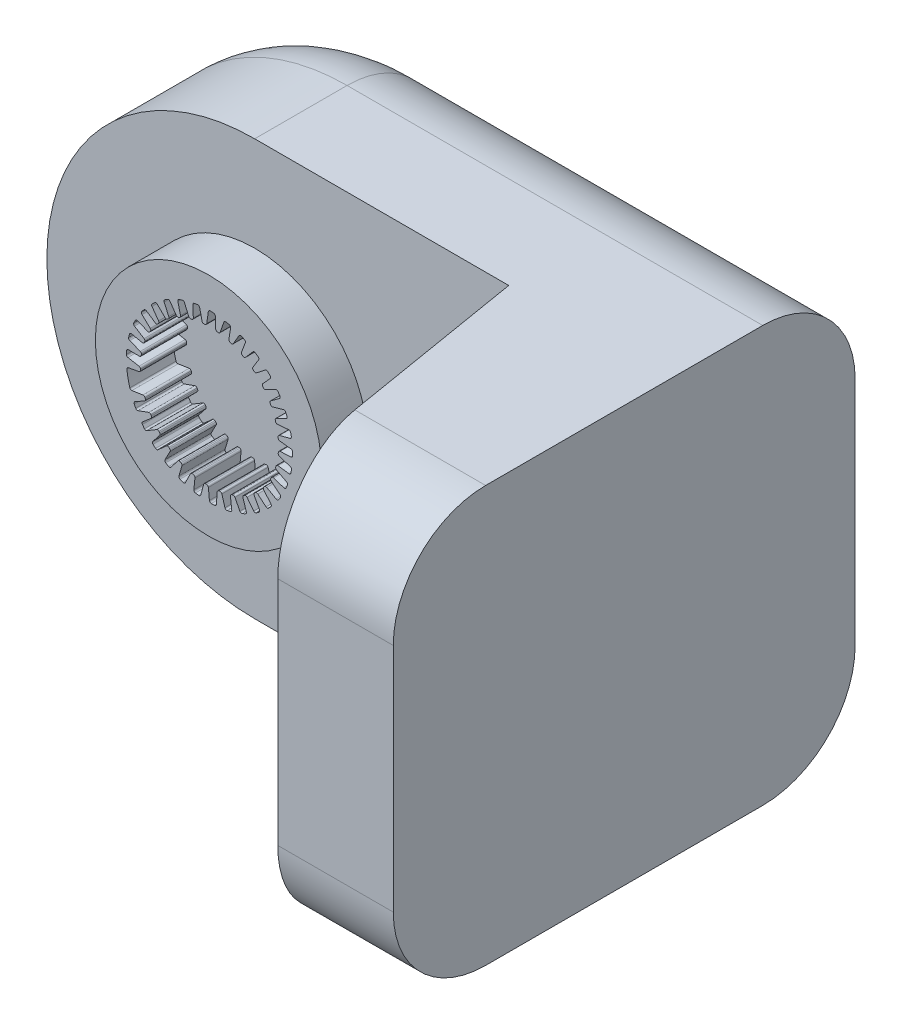
from build123d import *

# Parameters (mm, degrees)
SKETCH1_R           = 24.5
BOSS_EXTRUDE1_DEPTH = 10
BOSS_EXTRUDE3_DEPTH = 40
SKETCH7_W           = 35
SKETCH7_H           = 90
BOSS_EXTRUDE4_DEPTH = 60
CUT_EXTRUDE1_DEPTH  = 91
FILLET1_R           = 20
FILLET2_R           = 20


with BuildPart() as part:
    # Sketch1 → Boss-Extrude1 (new body)
    with BuildSketch(Plane.XY):
        with Locations((-0.371975008, 0)):
            Circle(SKETCH1_R)
        with BuildLine():
            Line((-16.969142825, -5.497864624), (-14.564977721, -5.124585631))
            ThreePointArc((-14.564977721, -5.124585631), (-14.29707046, -5.177296982), (-14.125400218, -5.389622476))
            Line((-14.125400218, -5.389622476), (-14.049847687, -5.60904296))
            ThreePointArc((-14.049847687, -5.60904296), (-14.054138659, -5.881349365), (-14.231761388, -6.087793926))
            Line((-14.231761388, -6.087793926), (-16.278130424, -7.240339372))
            ThreePointArc((-16.278130424, -7.240339372), (-16.462911631, -7.467282264), (-16.443705401, -7.759306734))
            ThreePointArc((-16.443705401, -7.759306734), (-16.284490349, -8.088614134), (-16.11861668, -8.414618309))
            ThreePointArc((-16.11861668, -8.414618309), (-15.909353928, -8.602256969), (-15.62830969, -8.605904202))
            Line((-15.62830969, -8.605904202), (-13.33954086, -7.780747067))
            ThreePointArc((-13.33954086, -7.780747067), (-13.06649801, -7.781370848), (-12.857468219, -7.957039097))
            Line((-12.857468219, -7.957039097), (-12.741436398, -8.158012106))
            ThreePointArc((-12.741436398, -8.158012106), (-12.693690022, -8.426134232), (-12.828657842, -8.662677839))
            Line((-12.828657842, -8.662677839), (-14.617513276, -10.1845134))
            ThreePointArc((-14.617513276, -10.1845134), (-14.755596786, -10.442544627), (-14.681022533, -10.725539064))
            ThreePointArc((-14.681022533, -10.725539064), (-14.461897897, -11.018416496), (-14.236867265, -11.306780868))
            ThreePointArc((-14.236867265, -11.306780868), (-13.995646114, -11.451042861), (-13.719069526, -11.400997316))
            Line((-13.719069526, -11.400997316), (-11.62979923, -10.15428296))
            ThreePointArc((-11.62979923, -10.15428296), (-11.361653923, -10.102796248), (-11.122945516, -10.235352213))
            Line((-11.122945516, -10.235352213), (-10.970698069, -10.410492867))
            ThreePointArc((-10.970698069, -10.410492867), (-10.872668815, -10.664578395), (-10.960022248, -10.922529105))
            Line((-10.960022248, -10.922529105), (-12.425631454, -12.757733968))
            ThreePointArc((-12.425631454, -12.757733968), (-12.511943302, -13.037372011), (-12.384741304, -13.300937604))
            ThreePointArc((-12.384741304, -13.300937604), (-12.113758956, -13.546623101), (-11.837840254, -13.786751538))
            ThreePointArc((-11.837840254, -13.786751538), (-11.57352453, -13.882335867), (-11.311578572, -13.780436499))
            Line((-11.311578572, -13.780436499), (-9.49857837, -12.157976231))
            ThreePointArc((-9.49857837, -12.157976231), (-9.245183775, -12.056270938), (-8.985568244, -12.140843765))
            Line((-8.985568244, -12.140843765), (-8.802699599, -12.28371641))
            ThreePointArc((-8.802699599, -12.28371641), (-8.657989614, -12.514428808), (-8.694518802, -12.784308057))
            Line((-8.694518802, -12.784308057), (-9.783027044, -14.865446458))
            ThreePointArc((-9.783027044, -14.865446458), (-9.814395646, -15.15641584), (-9.63924002, -15.390867705))
            ThreePointArc((-9.63924002, -15.390867705), (-9.326357378, -15.580333398), (-9.009689414, -15.763402229))
            ThreePointArc((-9.009689414, -15.763402229), (-8.731991565, -15.806796587), (-8.494301608, -15.656787752))
            Line((-8.494301608, -15.656787752), (-7.02419134, -13.718199902))
            ThreePointArc((-7.02419134, -13.718199902), (-6.794858602, -13.570013254), (-6.523875683, -13.603495261))
            Line((-6.523875683, -13.603495261), (-6.317105464, -13.70884995))
            ThreePointArc((-6.317105464, -13.70884995), (-6.131032208, -13.907711545), (-6.115394864, -14.179602449))
            Line((-6.115394864, -14.179602449), (-6.786804216, -16.430201641))
            ThreePointArc((-6.786804216, -16.430201641), (-6.762076913, -16.721810507), (-6.545403865, -16.918533562))
            ThreePointArc((-6.545403865, -16.918533562), (-6.202118, -17.044817414), (-5.856336939, -17.164099659))
            ThreePointArc((-5.856336939, -17.164099659), (-5.575461147, -17.153709492), (-5.370761259, -16.96110336))
            Line((-5.370761259, -16.96110336), (-4.297561057, -14.777622566))
            ThreePointArc((-4.297561057, -14.777622566), (-4.100717154, -14.588399775), (-3.828324286, -14.569560645))
            Line((-3.828324286, -14.569560645), (-3.605250396, -14.633526053))
            ThreePointArc((-3.605250396, -14.633526053), (-3.384651249, -14.79322955), (-3.317421976, -15.057141307))
            Line((-3.317421976, -15.057141307), (-3.547061077, -17.394501596))
            ThreePointArc((-3.547061077, -17.394501596), (-3.467146489, -17.676034594), (-3.216917807, -17.827800126))
            ThreePointArc((-3.216917807, -17.827800126), (-2.855842975, -17.886261756), (-2.49365476, -17.937374314))
            ThreePointArc((-2.49365476, -17.937374314), (-2.219921985, -17.873581416), (-2.055733994, -17.645455421))
            Line((-2.055733994, -17.645455421), (-1.418879279, -15.297315067))
            ThreePointArc((-1.418879279, -15.297315067), (-1.261757363, -15.074009244), (-0.997963795, -15.003541232))
            Line((-0.997963795, -15.003541232), (-0.766783225, -15.023766911))
            ThreePointArc((-0.766783225, -15.023766911), (-0.519764242, -15.138443903), (-0.403413423, -15.384678908))
            Line((-0.403413423, -15.384678908), (-0.182844038, -17.722912511))
            ThreePointArc((-0.182844038, -17.722912511), (-0.050678678, -17.984024533), (0.223910828, -18.085255821))
            ThreePointArc((0.223910828, -18.085255821), (0.589506703, -18.073747021), (0.954793236, -18.054811727))
            ThreePointArc((0.954793236, -18.054811727), (1.21132451, -17.939960209), (1.328967414, -17.684696986))
            Line((1.328967414, -17.684696986), (1.506075012, -15.258180974))
            ThreePointArc((1.506075012, -15.258180974), (1.617701396, -15.008997633), (1.863202402, -14.889490132))
            Line((1.863202402, -14.889490132), (2.093994776, -14.865232876))
            ThreePointArc((2.093994776, -14.865232876), (2.358356726, -14.930669484), (2.519553706, -15.150179676))
            Line((2.519553706, -15.150179676), (3.182226615, -17.403366719))
            ThreePointArc((3.182226615, -17.403366719), (3.361786248, -17.634463038), (3.650646611, -17.681440275))
            ThreePointArc((3.650646611, -17.681440275), (4.007329478, -17.600383942), (4.362291644, -17.512096587))
            ThreePointArc((4.362291644, -17.512096587), (4.592195013, -17.35040674), (4.658969966, -17.077386096))
            Line((4.658969966, -17.077386096), (4.369822517, -14.661658296))
            ThreePointArc((4.369822517, -14.661658296), (4.431851587, -14.395753836), (4.650038942, -14.231598224))
            Line((4.650038942, -14.231598224), (4.871962507, -14.163749381))
            ThreePointArc((4.871962507, -14.163749381), (5.143953277, -14.177541097), (5.344073133, -14.362260434))
            Line((5.344073133, -14.362260434), (6.424499231, -16.447606133))
            ThreePointArc((6.424499231, -16.447606133), (6.644855104, -16.640194968), (6.937371968, -16.631191945))
            ThreePointArc((6.937371968, -16.631191945), (7.272035289, -16.483566546), (7.603629778, -16.329171304))
            ThreePointArc((7.603629778, -16.329171304), (7.798457298, -16.126584524), (7.811910612, -15.845838777))
            Line((7.811910612, -15.845838777), (7.067133021, -13.529666635))
            ThreePointArc((7.067133021, -13.529666635), (7.077285479, -13.256811885), (7.260141751, -13.054040163))
            Line((7.260141751, -13.054040163), (7.465041785, -12.945092882))
            ThreePointArc((7.465041785, -12.945092882), (7.734666902, -12.906732919), (7.966356105, -13.049873773))
            Line((7.966356105, -13.049873773), (9.42483445, -14.89075078))
            ThreePointArc((9.42483445, -14.89075078), (9.677889447, -15.037755333), (9.963314095, -14.973102872))
            ThreePointArc((9.963314095, -14.973102872), (10.263660453, -14.764332996), (10.559702617, -14.549503217))
            ThreePointArc((10.559702617, -14.549503217), (10.712295226, -14.313463684), (10.671932552, -14.035309014))
            Line((10.671932552, -14.035309014), (9.498892143, -11.903801741))
            ThreePointArc((9.498892143, -11.903801741), (9.456794931, -11.634022921), (9.597600949, -11.400086065))
            Line((9.597600949, -11.400086065), (9.777948272, -11.254043683))
            ThreePointArc((9.777948272, -11.254043683), (10.03530019, -11.164941603), (10.290045172, -11.261244173))
            Line((10.290045172, -11.261244173), (12.072983054, -12.790008296))
            ThreePointArc((12.072983054, -12.790008296), (12.349438509, -12.886026792), (12.617282831, -12.768100588))
            ThreePointArc((12.617282831, -12.768100588), (12.872275811, -12.505857615), (13.121887392, -12.238487357))
            ThreePointArc((13.121887392, -12.238487357), (13.226637979, -11.977668492), (13.133942467, -11.712325868))
            Line((13.133942467, -11.712325868), (11.575743353, -9.84380705))
            ThreePointArc((11.575743353, -9.84380705), (11.48294336, -9.587017353), (11.576525119, -9.330511522))
            Line((11.576525119, -9.330511522), (11.725692753, -9.152740458))
            ThreePointArc((11.725692753, -9.152740458), (11.961314913, -9.016170373), (12.229754908, -9.062095959))
            Line((12.229754908, -9.062095959), (14.271637147, -10.222571794))
            ThreePointArc((14.271637147, -10.222571794), (14.561334529, -10.264075972), (14.801756416, -10.097209299))
            ThreePointArc((14.801756416, -10.097209299), (15.002026138, -9.791129513), (15.196035002, -9.481043465))
            ThreePointArc((15.196035002, -9.481043465), (15.24909444, -9.205029223), (15.107472246, -8.962248828))
            Line((15.107472246, -8.962248828), (13.22137144, -7.42537837))
            ThreePointArc((13.22137144, -7.42537837), (13.08127866, -7.191013697), (13.124197438, -6.921364359))
            Line((13.124197438, -6.921364359), (13.236704125, -6.718396924))
            ThreePointArc((13.236704125, -6.718396924), (13.441938441, -6.539377188), (13.714209453, -6.533238226))
            Line((13.714209453, -6.533238226), (15.940005792, -7.282783352))
            ThreePointArc((15.940005792, -7.282783352), (16.232299988, -7.268248115), (16.436464985, -7.058572594))
            ThreePointArc((16.436464985, -7.058572594), (16.574652412, -6.719903092), (16.705929579, -6.378495562))
            ThreePointArc((16.705929579, -6.378495562), (16.705348165, -6.09742826), (16.520003287, -5.886131214))
            Line((16.520003287, -5.886131214), (14.375306757, -4.737382395))
            ThreePointArc((14.375306757, -4.737382395), (14.193068988, -4.534054623), (14.183747708, -4.261170214))
            Line((14.183747708, -4.261170214), (14.255459317, -4.040464575))
            ThreePointArc((14.255459317, -4.040464575), (14.422764326, -3.825573383), (14.688861583, -3.767595452))
            Line((14.688861583, -3.767595452), (17.016783726, -4.07866736))
            ThreePointArc((17.016783726, -4.07866736), (17.300934201, -4.008626814), (17.461340136, -3.763847105))
            ThreePointArc((17.461340136, -3.763847105), (17.532367484, -3.405032512), (17.596089091, -3.044848735))
            ThreePointArc((17.596089091, -3.044848735), (17.54188819, -2.76905637), (17.319631242, -2.597006915))
            Line((17.319631242, -2.597006915), (14.99514722, -1.878591239))
            ThreePointArc((14.99514722, -1.878591239), (14.777460905, -1.713771776), (14.716242083, -1.447679606))
            Line((14.716242083, -1.447679606), (14.744523527, -1.217345731))
            ThreePointArc((14.744523527, -1.217345731), (14.867751498, -0.974479394), (15.117897089, -0.866792932))
            Line((15.117897089, -0.866792932), (17.462404064, -0.727961087))
            ThreePointArc((17.462404064, -0.727961087), (17.727969528, -0.604988917), (17.838722184, -0.334099605))
            ThreePointArc((17.838722184, -0.334099605), (17.839979507, 0.031675211), (17.833804064, 0.397400053))
            ThreePointArc((17.833804064, 0.397400053), (17.727975323, 0.657783316), (17.476973277, 0.784263113))
            Line((17.476973277, 0.784263113), (15.0581164, 1.045947009))
            ThreePointArc((15.0581164, 1.045947009), (14.812980559, 1.166201766), (14.70211372, 1.415723972))
            Line((14.70211372, 1.415723972), (14.685925779, 1.647222319))
            ThreePointArc((14.685925779, 1.647222319), (14.760548624, 1.909139522), (14.985550789, 2.06257751))
            Line((14.985550789, 2.06257751), (17.260492203, 2.646211643))
            ThreePointArc((17.260492203, 2.646211643), (17.497714285, 2.817596748), (17.554743986, 3.104641663))
            ThreePointArc((17.554743986, 3.104641663), (17.486185083, 3.463936074), (17.410339511, 3.821763191))
            ThreePointArc((17.410339511, 3.821763191), (17.256771672, 4.057169404), (16.986247758, 4.133431962))
            Line((16.986247758, 4.133431962), (14.561900453, 3.928768337))
            ThreePointArc((14.561900453, 3.928768337), (14.298322759, 4.000039553), (14.141881775, 4.223822943))
            Line((14.141881775, 4.223822943), (14.081819284, 4.447979208))
            ThreePointArc((14.081819284, 4.447979208), (14.105094939, 4.719322965), (14.296685833, 4.912874302))
            Line((14.296685833, 4.912874302), (16.418467522, 5.919864718))
            ThreePointArc((16.418467522, 5.919864718), (16.618629347, 6.133365102), (16.6198405, 6.426017974))
            ThreePointArc((16.6198405, 6.426017974), (16.483984611, 6.765629479), (16.341255904, 7.102410286))
            ThreePointArc((16.341255904, 7.102410286), (16.145591916, 7.304189299), (15.865486706, 7.327432303))
            Line((15.865486706, 7.327432303), (13.52473315, 6.663941652))
            ThreePointArc((13.52473315, 6.663941652), (13.252398931, 6.68361042), (13.056132325, 6.873431931))
            Line((13.056132325, 6.873431931), (12.95440232, 7.082009351))
            ThreePointArc((12.95440232, 7.082009351), (12.925475505, 7.352808963), (13.076614998, 7.579361483))
            Line((13.076614998, 7.579361483), (14.967270753, 8.972705682))
            ThreePointArc((14.967270753, 8.972705682), (15.123017247, 9.220476139), (15.068365347, 9.507983253))
            ThreePointArc((15.068365347, 9.507983253), (14.870204584, 9.815432612), (14.665837397, 10.118791886))
            ThreePointArc((14.665837397, 10.118791886), (14.435267057, 10.279529201), (14.155873194, 10.248898572))
            Line((14.155873194, 10.248898572), (11.984725859, 9.150961278))
            ThreePointArc((11.984725859, 9.150961278), (11.713642209, 9.118304857), (11.484761921, 9.267189378))
            Line((11.484761921, 9.267189378), (11.345102535, 9.452523643))
            ThreePointArc((11.345102535, 9.452523643), (11.265036185, 9.712828408), (11.370170562, 9.964057294))
            Line((11.370170562, 9.964057294), (12.960227038, 11.692555961))
            ThreePointArc((12.960227038, 11.692555961), (13.065835198, 11.965492009), (12.957328464, 12.237288733))
            ThreePointArc((12.957328464, 12.237288733), (12.704144369, 12.501278525), (12.445648304, 12.760069138))
            ThreePointArc((12.445648304, 12.760069138), (12.188644066, 12.87385836), (11.920228055, 12.79047964))
            Line((11.920228055, 12.79047964), (9.998467123, 11.298440105))
            ThreePointArc((9.998467123, 11.298440105), (9.738595182, 11.214658475), (9.485511563, 11.317135151))
            Line((9.485511563, 11.317135151), (9.313054669, 11.472416036))
            ThreePointArc((9.313054669, 11.472416036), (9.184790873, 11.712660889), (9.240056903, 11.979334578))
            Line((9.240056903, 11.979334578), (10.47108647, 13.979472934))
            ThreePointArc((10.47108647, 13.979472934), (10.522675657, 14.267545366), (10.364301238, 14.513644357))
            ThreePointArc((10.364301238, 14.513644357), (10.065397221, 14.724474111), (9.76227088, 14.929186636))
            ThreePointArc((9.76227088, 14.929186636), (9.488276526, 14.99184651), (9.240701483, 14.858783502))
            Line((9.240701483, 14.858783502), (7.638943277, 13.027467663))
            ThreePointArc((7.638943277, 13.027467663), (7.399832204, 12.895639434), (7.131844973, 12.947942693))
            Line((7.131844973, 12.947942693), (6.932927607, 13.067464305))
            ThreePointArc((6.932927607, 13.067464305), (6.7611795, 13.278821297), (6.764546399, 13.551140695))
            Line((6.764546399, 13.551140695), (7.591314094, 15.749422391))
            ThreePointArc((7.591314094, 15.749422391), (7.586988632, 16.042045802), (7.384566095, 16.253403998))
            ThreePointArc((7.384566095, 16.253403998), (7.050925573, 16.40332664), (6.714307526, 16.546438787))
            ThreePointArc((6.714307526, 16.546438787), (6.433391152, 16.555666835), (6.215754379, 16.377809024))
            Line((6.215754379, 16.377809024), (4.992856518, 14.274509741))
            ThreePointArc((4.992856518, 14.274509741), (4.783292601, 14.099479023), (4.510249118, 14.09968695))
            Line((4.510249118, 14.09968695), (4.292180626, 14.17905739))
            ThreePointArc((4.292180626, 14.17905739), (4.0832592, 14.353760076), (4.034603248, 14.621718634))
            Line((4.034603248, 14.621718634), (4.426728971, 16.937366417))
            ThreePointArc((4.426728971, 16.937366417), (4.3666478, 17.223788175), (4.127615291, 17.392639084))
            ThreePointArc((4.127615291, 17.392639084), (3.771498096, 17.476145612), (3.413757585, 17.552398635))
            ThreePointArc((3.413757585, 17.552398635), (3.136241642, 17.507855766), (2.956540339, 17.29173865))
            Line((2.956540339, 17.29173865), (2.15743898, 14.993742987))
            ThreePointArc((2.15743898, 14.993742987), (1.985122778, 14.781941396), (1.717056198, 14.73004635))
            Line((1.717056198, 14.73004635), (1.487849644, 14.766349102))
            ThreePointArc((1.487849644, 14.766349102), (1.249431849, 14.897977919), (1.150540941, 15.151729331))
            Line((1.150540941, 15.151729331), (1.093615783, 17.499653257))
            ThreePointArc((1.093615783, 17.499653257), (0.979986625, 17.769348613), (0.713127543, 17.889487702))
            ThreePointArc((0.713127543, 17.889487702), (0.347619428, 17.903509616), (-0.018098145, 17.910101548))
            ThreePointArc((-0.018098145, 17.910101548), (-0.282016159, 17.81342452), (-0.417178752, 17.566989459))
            Line((-0.417178752, 17.566989459), (-0.763120125, 15.15873872))
            ThreePointArc((-0.763120125, 15.15873872), (-0.891856745, 14.91794904), (-1.145096145, 14.815857937))
            Line((-1.145096145, 14.815857937), (-1.37701842, 14.807759033))
            ThreePointArc((-1.37701842, 14.807759033), (-1.636171771, 14.891477199), (-1.781663826, 15.121697207))
            Line((-1.781663826, 15.121697207), (-2.285548115, 17.415621326))
            ThreePointArc((-2.285548115, 17.415621326), (-2.448549885, 17.658680152), (-2.733429633, 17.725692835))
            ThreePointArc((-2.733429633, 17.725692835), (-3.094897842, 17.669714891), (-3.455153952, 17.606403508))
            ThreePointArc((-3.455153952, 17.606403508), (-3.695776202, 17.461144777), (-3.781433452, 17.193447184))
            Line((-3.781433452, 17.193447184), (-3.661503004, 14.763434069))
            ThreePointArc((-3.661503004, 14.763434069), (-3.741929532, 14.502504268), (-3.97103631, 14.353968511))
            Line((-3.97103631, 14.353968511), (-4.197152176, 14.30176555))
            ThreePointArc((-4.197152176, 14.30176555), (-4.467518329, 14.334496787), (-4.654265334, 14.532725812))
            Line((-4.654265334, 14.532725812), (-5.586593206, 16.688358429))
            ThreePointArc((-5.586593206, 16.688358429), (-5.792977985, 16.895849376), (-6.085410312, 16.907273229))
            ThreePointArc((-6.085410312, 16.907273229), (-6.429556237, 16.783352371), (-6.771113046, 16.65246409))
            ThreePointArc((-6.771113046, 16.65246409), (-6.979597716, 16.463961282), (-7.012602092, 16.184837873))
            Line((-7.012602092, 16.184837873), (-6.431206742, 13.822354752))
            ThreePointArc((-6.431206742, 13.822354752), (-6.460367855, 13.550872862), (-6.656923338, 13.36135049))
            Line((-6.656923338, 13.36135049), (-6.868924024, 13.266961704))
            ThreePointArc((-6.868924024, 13.266961704), (-7.140568204, 13.247503281), (-7.361708022, 13.406457273))
            Line((-7.361708022, 13.406457273), (-8.688220498, 15.344588302))
            ThreePointArc((-8.688220498, 15.344588302), (-8.930404547, 15.508886984), (-9.219643842, 15.46430223))
            ThreePointArc((-9.219643842, 15.46430223), (-9.533821622, 15.276992009), (-9.84412841, 15.083336403))
            ThreePointArc((-9.84412841, 15.083336403), (-10.012814597, 14.858516172), (-9.991953333, 14.578223515))
            Line((-9.991953333, 14.578223515), (-8.970456822, 12.370081325))
            ThreePointArc((-8.970456822, 12.370081325), (-8.947280977, 12.098023119), (-9.104062609, 11.874478253))
            Line((-9.104062609, 11.874478253), (-9.294158016, 11.741372016))
            ThreePointArc((-9.294158016, 11.741372016), (-9.557098485, 11.670438947), (-9.804505193, 11.784277039))
            Line((-9.804505193, 11.784277039), (-11.476458734, 13.43368863))
            ThreePointArc((-11.476458734, 13.43368863), (-11.745542845, 13.548757787), (-12.020960828, 13.449802721))
            ThreePointArc((-12.020960828, 13.449802721), (-12.293625803, 13.20598597), (-12.561280149, 12.956679036))
            ThreePointArc((-12.561280149, 12.956679036), (-12.683969373, 12.703802544), (-12.610009029, 12.43264017))
            Line((-12.610009029, 12.43264017), (-11.185946893, 10.459978494))
            ThreePointArc((-11.185946893, 10.459978494), (-11.1112857, 10.197340923), (-11.222532441, 9.947987861))
            Line((-11.222532441, 9.947987861), (-11.383737393, 9.781055247))
            ThreePointArc((-11.383737393, 9.781055247), (-11.628312237, 9.661254011), (-11.892894719, 9.725793152))
            Line((-11.892894719, 9.725793152), (-13.848852332, 11.02587663))
            ThreePointArc((-13.848852332, 11.02587663), (-14.134948842, 11.087487974), (-14.386425104, 10.937798763))
            ThreePointArc((-14.386425104, 10.937798763), (-14.607558025, 10.646434682), (-14.822724802, 10.350637362))
            ThreePointArc((-14.822724802, 10.350637362), (-14.89490877, 10.078996716), (-14.770567065, 9.826928657))
            Line((-14.770567065, 9.826928657), (-12.996267369, 8.162234197))
            ThreePointArc((-12.996267369, 8.162234197), (-12.872864302, 7.918668046), (-12.934488319, 7.652669423))
            Line((-12.934488319, 7.652669423), (-13.060879237, 7.458044476))
            ThreePointArc((-13.060879237, 7.458044476), (-13.278101399, 7.293777246), (-13.550137405, 7.306645904))
            Line((-13.550137405, 7.306645904), (-15.71822619, 8.209628879))
            ThreePointArc((-15.71822619, 8.209628879), (-16.010822299, 8.215518462), (-16.229116186, 8.02059553))
            ThreePointArc((-16.229116186, 8.02059553), (-16.390591385, 7.692390478), (-16.545364153, 7.360972031))
            ThreePointArc((-16.545364153, 7.360972031), (-16.56439042, 7.080548838), (-16.394236369, 6.856837495))
            Line((-16.394236369, 6.856837495), (-14.334896879, 5.561280504))
            ThreePointArc((-14.334896879, 5.561280504), (-14.16728646, 5.345735764), (-14.177023341, 5.072865868))
            Line((-14.177023341, 5.072865868), (-14.263955911, 4.857700206))
            ThreePointArc((-14.263955911, 4.857700206), (-14.445843425, 4.655003085), (-14.715336818, 4.615728392))
            Line((-14.715336818, 4.615728392), (-17.015888981, 5.088430184))
            ThreePointArc((-17.015888981, 5.088430184), (-17.304233061, 5.038381589), (-17.481323225, 4.805387503))
            ThreePointArc((-17.481323225, 4.805387503), (-17.577207194, 4.452401581), (-17.665898729, 4.097540189))
            ThreePointArc((-17.665898729, 4.097540189), (-17.631068162, 3.818638777), (-17.421354184, 3.631504565))
            Line((-17.421354184, 3.631504565), (-15.152646632, 2.752691104))
            ThreePointArc((-15.152646632, 2.752691104), (-14.946987814, 2.573088104), (-14.90447977, 2.303373712))
            Line((-14.90447977, 2.303373712), (-14.9487596, 2.075573732))
            ThreePointArc((-14.9487596, 2.075573732), (-15.088628894, 1.841894954), (-15.34567697, 1.751920085))
            Line((-15.34567697, 1.751920085), (-17.694157264, 1.776970967))
            ThreePointArc((-17.694157264, 1.776970967), (-17.967653929, 1.672823261), (-18.09703308, 1.410319536))
            ThreePointArc((-18.09703308, 1.410319536), (-18.123802502, 1.045523436), (-18.143153778, 0.680258704))
            ThreePointArc((-18.143153778, 0.680258704), (-18.055746248, 0.413127482), (-17.814178415, 0.269446766))
            Line((-17.814178415, 0.269446766), (-15.419467897, -0.160330607))
            ThreePointArc((-15.419467897, -0.160330607), (-15.183317743, -0.297392242), (-15.090126759, -0.554040304))
            Line((-15.090126759, -0.554040304), (-15.090126759, -0.786103946))
            ThreePointArc((-15.090126759, -0.786103946), (-15.182838247, -1.042177706), (-15.417995612, -1.179546569))
            Line((-15.417995612, -1.179546569), (-17.728107642, -1.603067108))
            ThreePointArc((-17.728107642, -1.603067108), (-17.976707083, -1.757486951), (-18.053621104, -2.039854449))
            ThreePointArc((-18.053621104, -2.039854449), (-17.805412438, -3.642620368), (-17.413942426, -5.216538207))
            ThreePointArc((-17.413942426, -5.216538207), (-17.244327564, -5.440658632), (-16.969142825, -5.497864624))
        make_face(mode=Mode.SUBTRACT)
    extrude(amount=BOSS_EXTRUDE1_DEPTH)

    # Sketch6 → Boss-Extrude3 (add)
    with BuildSketch(Plane.XY):
        with BuildLine():
            Line((-0.371975008, 45), (89.628024992, 45))
            Line((89.628024992, 45), (89.628024992, -45))
            Line((89.628024992, -45), (-0.371975008, -45))
            ThreePointArc((-0.371975008, -45), (-45.371975008, 0), (-0.371975008, 45))
        make_face()
    extrude(amount=-BOSS_EXTRUDE3_DEPTH)

    # Sketch7 → Boss-Extrude4 (add)
    with BuildSketch(Plane.XY):
        with Locations((72.128024992, 0)):
            Rectangle(SKETCH7_W, SKETCH7_H)
    extrude(amount=BOSS_EXTRUDE4_DEPTH)

    # Sketch8 → Cut-Extrude1 (cut, through all)
    with BuildSketch(Plane(origin=(0, 45, 0), x_dir=(1, 0, 0), z_dir=(0, 1, 0))):
        Polygon((54.628024992, 0), (64.628024992, -60), (54.628024992, -60), align=None)
    extrude(amount=-CUT_EXTRUDE1_DEPTH, mode=Mode.SUBTRACT)

    # Fillet1
    fillet1_edges = [part.edges().sort_by_distance(p)[0] for p in [
        (44.628024992, -45, -40),
        (-45.371975008, 0, -40),
        (44.628024992, 45, -40),
    ]]
    fillet(fillet1_edges, radius=FILLET1_R)

    # Fillet2
    fillet2_edges = [part.edges().sort_by_distance(p)[0] for p in [
        (77.128024992, 45, 60),
        (77.128024992, -45, 60),
    ]]
    fillet(fillet2_edges, radius=FILLET2_R)


solid = part.part
